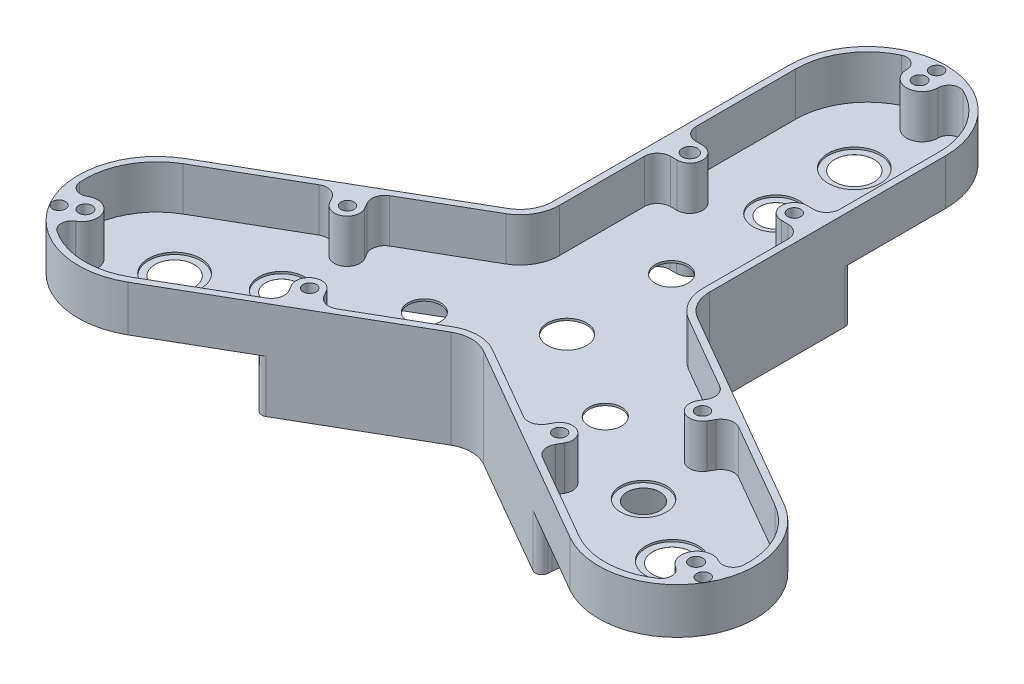
from build123d import *

# Parameters (mm, degrees)
BOSS_EXTRUDE3_DEPTH = 22.225
CUT_EXTRUDE3_DEPTH  = 21.209
SKETCH22_R          = 9.525
CUT_EXTRUDE4_DEPTH  = 22.224746
SKETCH23_R          = 7.9375
CUT_EXTRUDE5_DEPTH  = 22.224746
SKETCH26_R          = 3.673556043
CUT_EXTRUDE8_DEPTH  = 25.4
SKETCH27_R          = 3.175
CUT_EXTRUDE9_DEPTH  = 25.4
SKETCH28_R          = 3.175
CUT_EXTRUDE24_DEPTH = 25.4
SKETCH35_R          = 3.175
SKETCH35_R_2        = 3.2639
CUT_EXTRUDE25_DEPTH = 9.525
SKETCH36_R          = 3.2639
SKETCH36_R_2        = 7.9375
SKETCH36_R_3        = 9.525
CUT_EXTRUDE30_DEPTH = 25.4
SKETCH48_R          = 3.673556043
SKETCH48_R_2        = 7.9375
SKETCH48_R_3        = 3.175
SKETCH48_R_4        = 9.525
BOSS_EXTRUDE4_DEPTH = 25.4
CUT_EXTRUDE31_DEPTH = 25.4
SKETCH50_R          = 3.175
CUT_EXTRUDE32_DEPTH = 9.525
SKETCH55_R          = 11.1125
SKETCH55_R_2        = 12.7
CUT_EXTRUDE36_DEPTH = 0.9906


with BuildPart() as part:
    # Sketch1 → Boss-Extrude3 (new body)
    with BuildSketch(Plane(origin=(0, 0, 0), x_dir=(1, 0, 0), z_dir=(0, 1, 0))):
        with BuildLine():
            Line((-38.1, 31.16248078), (-38.1, 146.05))
            ThreePointArc((-38.1, 146.05), (0, 184.15), (38.1, 146.05))
            Line((38.1, 146.05), (38.1, 31.16248078))
            ThreePointArc((38.1, 31.16248078), (40.226846715, 23.22498078), (46.0375, 17.414327494))
            Line((46.0375, 17.414327494), (145.533010223, -40.029432116))
            ThreePointArc((145.533010223, -40.029432116), (159.478578107, -92.075), (107.433010223, -106.020567884))
            Line((107.433010223, -106.020567884), (7.9375, -48.576808274))
            ThreePointArc((7.9375, -48.576808274), (0, -46.449961559), (-7.9375, -48.576808274))
            Line((-7.9375, -48.576808274), (-107.433010223, -106.020567884))
            ThreePointArc((-107.433010223, -106.020567884), (-159.478578107, -92.075), (-145.533010223, -40.029432116))
            Line((-145.533010223, -40.029432116), (-46.0375, 17.414327494))
            ThreePointArc((-46.0375, 17.414327494), (-40.226846715, 23.22498078), (-38.1, 31.16248078))
        make_face()
    extrude(amount=BOSS_EXTRUDE3_DEPTH)

    # Sketch17 → Cut-Extrude3 (cut)
    with BuildSketch(Plane(origin=(0, 22.225, 0), x_dir=(1, 0, 0), z_dir=(0, 1, 0))):
        with BuildLine():
            ThreePointArc((25.4, 78.86090476), (19.17090476, 85.09), (25.4, 91.31909524))
            Line((25.4, 91.31909524), (28.575, 91.31909524))
            ThreePointArc((28.575, 91.31909524), (33.065128061, 93.178967179), (34.925, 97.66909524))
            Line((34.925, 97.66909524), (34.925, 146.05))
            ThreePointArc((34.925, 146.05), (29.534644698, 164.690289364), (15.027483173, 177.576661328))
            ThreePointArc((15.027483173, 177.576661328), (10.007581005, 177.205607558), (7.619805836, 172.774396841))
            ThreePointArc((7.619805836, 172.774396841), (0.027198595, 165.100048539), (-7.62, 172.719999998))
            ThreePointArc((-7.62, 172.719999998), (-7.619951459, 172.747198592), (-7.619805836, 172.774396841))
            ThreePointArc((-7.619805836, 172.774396841), (-10.007581005, 177.205607558), (-15.027483173, 177.576661328))
            ThreePointArc((-15.027483173, 177.576661328), (-29.534644698, 164.690289364), (-34.925, 146.05))
            Line((-34.925, 146.05), (-34.925, 97.66909524))
            ThreePointArc((-34.925, 97.66909524), (-33.065128061, 93.178967179), (-28.575, 91.31909524))
            Line((-28.575, 91.31909524), (-25.4, 91.31909524))
            ThreePointArc((-25.4, 91.31909524), (-19.17090476, 85.09), (-25.4, 78.86090476))
            Line((-25.4, 78.86090476), (-28.575, 78.86090476))
            ThreePointArc((-28.575, 78.86090476), (-33.065128061, 77.001032821), (-34.925, 72.51090476))
            Line((-34.925, 72.51090476), (-34.925, 31.16248078))
            ThreePointArc((-34.925, 31.16248078), (-37.477216058, 21.63748078), (-44.45, 14.664696837))
            Line((-44.45, 14.664696837), (-80.258785574, -6.009515153))
            ThreePointArc((-80.258785574, -6.009515153), (-83.217414571, -9.865275531), (-82.583046888, -14.683776467))
            Line((-82.583046888, -14.683776467), (-80.995546888, -17.433407124))
            ThreePointArc((-80.995546888, -17.433407124), (-83.275553988, -25.942509464), (-91.784656328, -23.662502364))
            Line((-91.784656328, -23.662502364), (-93.372156328, -20.912871707))
            ThreePointArc((-93.372156328, -20.912871707), (-97.227916706, -17.95424271), (-102.046417642, -18.588610393))
            Line((-102.046417642, -18.588610393), (-143.945510223, -42.779062773))
            ThreePointArc((-143.945510223, -42.779062773), (-157.393296695, -56.767392082), (-161.299641416, -75.774148481))
            ThreePointArc((-161.299641416, -75.774148481), (-158.459050418, -79.917771869), (-153.43691971, -79.788252996))
            ThreePointArc((-153.43691971, -79.788252996), (-142.994435502, -82.526469598), (-145.769907744, -92.959113578))
            Line((-145.769907744, -92.959113578), (-145.900114004, -93.034288197))
            ThreePointArc((-145.900114004, -93.034288197), (-148.463020777, -97.317547011), (-146.272158243, -101.802512847))
            ThreePointArc((-146.272158243, -101.802512847), (-127.858651998, -107.922897282), (-109.020510223, -103.270937227))
            Line((-109.020510223, -103.270937227), (-67.121417642, -79.080484847))
            ThreePointArc((-67.121417642, -79.080484847), (-64.162788645, -75.224724469), (-64.797156328, -70.406223533))
            Line((-64.797156328, -70.406223533), (-66.384656328, -67.656592876))
            ThreePointArc((-66.384656328, -67.656592876), (-64.104649228, -59.147490536), (-55.595546888, -61.427497636))
            Line((-55.595546888, -61.427497636), (-54.008046888, -64.177128293))
            ThreePointArc((-54.008046888, -64.177128293), (-50.15228651, -67.13575729), (-45.333785574, -66.501389607))
            Line((-45.333785574, -66.501389607), (-9.525, -45.827177617))
            ThreePointArc((-9.525, -45.827177617), (0, -43.274961559), (9.525, -45.827177617))
            Line((9.525, -45.827177617), (45.333785574, -66.501389607))
            ThreePointArc((45.333785574, -66.501389607), (50.15228651, -67.13575729), (54.008046888, -64.177128293))
            Line((54.008046888, -64.177128293), (55.595546888, -61.427497636))
            ThreePointArc((55.595546888, -61.427497636), (64.104649228, -59.147490536), (66.384656328, -67.656592876))
            Line((66.384656328, -67.656592876), (64.797156328, -70.406223533))
            ThreePointArc((64.797156328, -70.406223533), (64.162788645, -75.224724469), (67.121417642, -79.080484847))
            Line((67.121417642, -79.080484847), (109.020510223, -103.270937227))
            ThreePointArc((109.020510223, -103.270937227), (127.858651998, -107.922897282), (146.272158243, -101.802512847))
            ThreePointArc((146.272158243, -101.802512847), (148.462560886, -97.306961314), (145.881859604, -93.023524818))
            Line((145.881859604, -93.023524818), (145.817113869, -92.986143851))
            ThreePointArc((145.817113869, -92.986143851), (142.967236903, -82.573578948), (153.38990774, -79.760886427))
            Line((153.38990774, -79.760886427), (153.5201137, -79.836060873))
            ThreePointArc((153.5201137, -79.836060873), (158.51097818, -79.913974091), (161.299641416, -75.774148481))
            ThreePointArc((161.299641416, -75.774148481), (157.393296695, -56.767392082), (143.945510223, -42.779062773))
            Line((143.945510223, -42.779062773), (102.046417642, -18.588610393))
            ThreePointArc((102.046417642, -18.588610393), (97.227916706, -17.95424271), (93.372156328, -20.912871707))
            Line((93.372156328, -20.912871707), (91.784656328, -23.662502364))
            ThreePointArc((91.784656328, -23.662502364), (83.275553988, -25.942509464), (80.995546888, -17.433407124))
            Line((80.995546888, -17.433407124), (82.583046888, -14.683776467))
            ThreePointArc((82.583046888, -14.683776467), (83.217414571, -9.865275531), (80.258785574, -6.009515153))
            Line((80.258785574, -6.009515153), (44.45, 14.664696837))
            ThreePointArc((44.45, 14.664696837), (37.477216058, 21.63748078), (34.925, 31.16248078))
            Line((34.925, 31.16248078), (34.925, 72.51090476))
            ThreePointArc((34.925, 72.51090476), (33.065128061, 77.001032821), (28.575, 78.86090476))
            Line((28.575, 78.86090476), (25.4, 78.86090476))
        make_face()
    extrude(amount=-CUT_EXTRUDE3_DEPTH, mode=Mode.SUBTRACT)

    # Sketch22 → Cut-Extrude4 (cut)
    with BuildSketch(Plane(origin=(0, 1.016, 0), x_dir=(1, 0, 0), z_dir=(0, 1, 0))):
        Circle(SKETCH22_R)
    extrude(amount=-CUT_EXTRUDE4_DEPTH, mode=Mode.SUBTRACT)

    # Sketch23 → Cut-Extrude5 (cut)
    with BuildSketch(Plane(origin=(0, 1.016, 0), x_dir=(1, 0, 0), z_dir=(0, 1, 0))):
        with Locations((0, 50.8)):
            Circle(SKETCH23_R)
        with Locations((43.994090512, -25.4)):
            Circle(SKETCH23_R)
        with Locations((-43.994090512, -25.4)):
            Circle(SKETCH23_R)
    extrude(amount=-CUT_EXTRUDE5_DEPTH, mode=Mode.SUBTRACT)

    # Sketch26 → Cut-Extrude8 (cut)
    with BuildSketch(Plane(origin=(0, 22.225, 0), x_dir=(1, 0, 0), z_dir=(0, 1, 0))):
        with Locations((-25.4, 85.09)):
            Circle(SKETCH26_R)
    extrude(amount=-CUT_EXTRUDE8_DEPTH, mode=Mode.SUBTRACT)

    # Sketch27 → Cut-Extrude9 (cut)
    with BuildSketch(Plane(origin=(0, 22.225, 0), x_dir=(1, 0, 0), z_dir=(0, 1, 0))):
        with Locations((25.4, 85.09)):
            Circle(SKETCH27_R)
    extrude(amount=-CUT_EXTRUDE9_DEPTH, mode=Mode.SUBTRACT)

    # Sketch28 → Cut-Extrude24 (cut)
    with BuildSketch(Plane(origin=(0, 22.225, 0), x_dir=(1, 0, 0), z_dir=(0, 1, 0))):
        with Locations((-86.285395014, -20.487502364)):
            Circle(SKETCH28_R)
        with Locations((-60.73873104, -64.396916391)):
            Circle(SKETCH28_R)
        with Locations((60.885395014, -64.481592876)):
            Circle(SKETCH28_R)
        with Locations((86.460019457, -20.588321833)):
            Circle(SKETCH28_R)
    extrude(amount=-CUT_EXTRUDE24_DEPTH, mode=Mode.SUBTRACT)

    # Sketch35 → Cut-Extrude25 (cut)
    with BuildSketch(Plane(origin=(0, 22.225, 0), x_dir=(1, 0, 0), z_dir=(0, 1, 0))):
        with Locations((0, 179.705)):
            Circle(SKETCH35_R)
        with Locations((156.618962224, -90.424)):
            Circle(SKETCH35_R)
        with Locations((-156.618962224, -90.424)):
            Circle(SKETCH35_R)
        with Locations((0, 171.45)):
            Circle(SKETCH35_R_2)
    extrude(amount=-CUT_EXTRUDE25_DEPTH, mode=Mode.SUBTRACT)

    # Sketch36 → Cut-Extrude30 (cut)
    with BuildSketch(Plane(origin=(0, 22.225, 0), x_dir=(1, 0, 0), z_dir=(0, 1, 0))):
        with Locations((0, 171.45)):
            Circle(SKETCH36_R)
        with Locations((148.480055479, -85.725)):
            Circle(SKETCH36_R)
        with Locations((-148.480055479, -85.725)):
            Circle(SKETCH36_R)
        with Locations((0, 50.8)):
            Circle(SKETCH36_R_2)
        with Locations((0, 101.6)):
            Circle(SKETCH36_R_2)
        with Locations((0, 139.7)):
            Circle(SKETCH36_R_3)
        with Locations((120.983748909, -69.85)):
            Circle(SKETCH36_R_3)
        with Locations((87.988181025, -50.8)):
            Circle(SKETCH36_R_2)
        with Locations((-120.983748909, -69.85)):
            Circle(SKETCH36_R_3)
        with Locations((-87.988181024, -50.8)):
            Circle(SKETCH36_R_2)
    extrude(amount=-CUT_EXTRUDE30_DEPTH, mode=Mode.SUBTRACT)

    # Sketch48 → Boss-Extrude4 (add)
    with BuildSketch(Plane.XZ):
        with BuildLine():
            Line((64.934223532, 81.483881948), (7.9375, 48.576808274))
            ThreePointArc((7.9375, 48.576808274), (0, 46.449961559), (-7.9375, 48.576808274))
            Line((-7.9375, 48.576808274), (-64.934223532, 81.483881948))
            ThreePointArc((-64.934223532, 81.483881948), (-68.045575265, 81.51965986), (-69.693365764, 78.880232623))
            Line((-69.693365764, 78.880232623), (-69.775610399, 77.093356509))
            ThreePointArc((-69.775610399, 77.093356509), (-79.662299395, 45.99305), (-101.652610399, 21.880772916))
            Line((-101.652610399, 21.880772916), (-103.15896819, 20.916108915))
            ThreePointArc((-103.15896819, 20.916108915), (-104.620883979, 18.169366865), (-103.034223532, 15.49274618))
            Line((-103.034223532, 15.49274618), (-46.0375, -17.414327494))
            ThreePointArc((-46.0375, -17.414327494), (-40.226846715, -23.224980779), (-38.1, -31.162480779))
            Line((-38.1, -31.162480779), (-38.1, -96.976628128))
            ThreePointArc((-38.1, -96.976628128), (-36.575308714, -99.689026724), (-33.465602426, -99.796341539))
            Line((-33.465602426, -99.796341539), (-31.877, -98.974129424))
            ThreePointArc((-31.877, -98.974129424), (0, -91.9861), (31.877, -98.974129424))
            Line((31.877, -98.974129424), (33.465602426, -99.796341539))
            ThreePointArc((33.465602426, -99.796341539), (36.575308714, -99.689026724), (38.1, -96.976628128))
            Line((38.1, -96.976628128), (38.1, -31.16248078))
            ThreePointArc((38.1, -31.16248078), (40.226846715, -23.22498078), (46.0375, -17.414327494))
            Line((46.0375, -17.414327494), (103.034223532, 15.49274618))
            ThreePointArc((103.034223532, 15.49274618), (104.620883979, 18.169366865), (103.15896819, 20.916108915))
            Line((103.15896819, 20.916108915), (101.652610399, 21.880772916))
            ThreePointArc((101.652610399, 21.880772916), (79.662299395, 45.99305), (69.775610399, 77.093356508))
            Line((69.775610399, 77.093356508), (69.693365764, 78.880232623))
            ThreePointArc((69.693365764, 78.880232623), (68.045575265, 81.51965986), (64.934223532, 81.483881948))
        make_face()
        with Locations((-25.4, -85.09)):
            Circle(SKETCH48_R, mode=Mode.SUBTRACT)
        with Locations((0, -50.8)):
            Circle(SKETCH48_R_2, mode=Mode.SUBTRACT)
        with Locations((25.4, -85.09)):
            Circle(SKETCH48_R_3, mode=Mode.SUBTRACT)
        with Locations((-86.285395014, 20.487502364)):
            Circle(SKETCH48_R_3, mode=Mode.SUBTRACT)
        Circle(SKETCH48_R_4, mode=Mode.SUBTRACT)
        with Locations((-43.994090512, 25.4)):
            Circle(SKETCH48_R_2, mode=Mode.SUBTRACT)
        with Locations((-60.73873104, 64.396916391)):
            Circle(SKETCH48_R_3, mode=Mode.SUBTRACT)
        with Locations((43.994090512, 25.4)):
            Circle(SKETCH48_R_2, mode=Mode.SUBTRACT)
        with Locations((86.460019457, 20.588321833)):
            Circle(SKETCH48_R_3, mode=Mode.SUBTRACT)
        with Locations((60.885395014, 64.481592876)):
            Circle(SKETCH48_R_3, mode=Mode.SUBTRACT)
    extrude(amount=BOSS_EXTRUDE4_DEPTH)

    # Sketch49 → Cut-Extrude31 (cut)
    with BuildSketch(Plane.XZ.offset(25.4)):
        with BuildLine():
            Line((55.3861337, 61.306592876), (53.7986337, 64.056223533))
            ThreePointArc((53.7986337, 64.056223533), (49.942873323, 67.01485253), (45.124372386, 66.380484847))
            Line((45.124372386, 66.380484847), (9.525, 45.827177617))
            Line((9.525, 45.827177617), (8.122207895, 45.017275217))
            ThreePointArc((8.122207895, 45.017275217), (0.765194607, 42.901045118), (-6.726805893, 44.47394145))
            Line((-6.726805893, 44.47394145), (-9.525, 45.827177617))
            Line((-9.525, 45.827177617), (-45.124372386, 66.380484847))
            ThreePointArc((-45.124372386, 66.380484847), (-49.942873323, 67.01485253), (-53.7986337, 64.056223533))
            Line((-53.7986337, 64.056223533), (-55.3861337, 61.306592876))
            ThreePointArc((-55.3861337, 61.306592876), (-57.710395014, 58.982331562), (-60.885395014, 58.131592876))
            Line((-60.885395014, 58.131592876), (-66.336321036, 58.131592876))
            ThreePointArc((-66.336321036, 58.131592876), (-69.469372125, 57.30486101), (-71.78661434, 55.039936459))
            ThreePointArc((-71.78661434, 55.039936459), (-76.912668738, 44.40555), (-83.559290366, 34.649063441))
            ThreePointArc((-83.559290366, 34.649063441), (-84.362151457, 31.50981054), (-83.511596711, 28.383142773))
            Line((-83.511596711, 28.383142773), (-80.7861337, 23.662502364))
            ThreePointArc((-80.7861337, 23.662502364), (-79.935395014, 20.487502364), (-80.7861337, 17.312502364))
            Line((-80.7861337, 17.312502364), (-82.3736337, 14.562871707))
            ThreePointArc((-82.3736337, 14.562871707), (-83.008001383, 9.74437077), (-80.049372386, 5.888610393))
            Line((-80.049372386, 5.888610393), (-44.45, -14.664696837))
            Line((-44.45, -14.664696837), (-43.047207895, -15.474599237))
            ThreePointArc((-43.047207895, -15.474599237), (-37.535992224, -20.787844591), (-35.152160156, -28.062555515))
            Line((-35.152160156, -28.062555515), (-34.925, -31.16248078))
            Line((-34.925, -31.16248078), (-34.925, -72.26909524))
            ThreePointArc((-34.925, -72.26909524), (-33.065128061, -76.7592233), (-28.575, -78.61909524))
            Line((-28.575, -78.61909524), (-25.4, -78.61909524))
            ThreePointArc((-25.4, -78.61909524), (-22.225, -79.469833926), (-19.900738686, -81.79409524))
            Line((-19.900738686, -81.79409524), (-17.175275675, -86.514735649))
            ThreePointArc((-17.175275675, -86.514735649), (-14.892779332, -88.81467155), (-11.772676026, -89.688999899))
            ThreePointArc((-11.772676026, -89.688999899), (0, -88.8111), (11.772676026, -89.688999899))
            ThreePointArc((11.772676026, -89.688999899), (14.892779332, -88.81467155), (17.175275675, -86.514735649))
            Line((17.175275675, -86.514735649), (19.900738686, -81.79409524))
            ThreePointArc((19.900738686, -81.79409524), (22.225, -79.469833926), (25.4, -78.61909524))
            Line((25.4, -78.61909524), (28.575, -78.61909524))
            ThreePointArc((28.575, -78.61909524), (33.065128061, -76.7592233), (34.925, -72.26909524))
            Line((34.925, -72.26909524), (34.925, -31.16248078))
            Line((34.925, -31.16248078), (35.152160156, -28.062555515))
            ThreePointArc((35.152160156, -28.062555515), (37.535992224, -20.787844591), (43.047207895, -15.474599237))
            Line((43.047207895, -15.474599237), (44.45, -14.664696837))
            Line((44.45, -14.664696837), (80.049372386, 5.888610393))
            ThreePointArc((80.049372386, 5.888610393), (83.008001383, 9.74437077), (82.3736337, 14.562871707))
            Line((82.3736337, 14.562871707), (80.7861337, 17.312502364))
            ThreePointArc((80.7861337, 17.312502364), (79.935395014, 20.487502364), (80.7861337, 23.662502364))
            Line((80.7861337, 23.662502364), (83.511596711, 28.383142773))
            ThreePointArc((83.511596711, 28.383142773), (84.362151457, 31.50981054), (83.559290366, 34.649063441))
            ThreePointArc((83.559290366, 34.649063441), (76.912668738, 44.40555), (71.78661434, 55.039936459))
            ThreePointArc((71.78661434, 55.039936459), (69.469372125, 57.30486101), (66.336321036, 58.131592876))
            Line((66.336321036, 58.131592876), (60.885395014, 58.131592876))
            ThreePointArc((60.885395014, 58.131592876), (57.710395014, 58.982331562), (55.3861337, 61.306592876))
        make_face()
    extrude(amount=-CUT_EXTRUDE31_DEPTH, mode=Mode.SUBTRACT)

    # Sketch50 → Cut-Extrude32 (cut)
    with BuildSketch(Plane(origin=(0, -25.4, 0), x_dir=(-1, 0, 0), z_dir=(0, -1, 0))):
        with Locations((-65.035301623, -74.356537961)):
            Circle(SKETCH50_R)
        with Locations((-96.912301623, -19.143954368)):
            Circle(SKETCH50_R)
        with Locations((-31.877, 93.500492328)):
            Circle(SKETCH50_R)
        with Locations((31.877, 93.500492328)):
            Circle(SKETCH50_R)
        with Locations((65.035301623, -74.356537961)):
            Circle(SKETCH50_R)
        with Locations((96.912301623, -19.143954368)):
            Circle(SKETCH50_R)
    extrude(amount=-CUT_EXTRUDE32_DEPTH, mode=Mode.SUBTRACT)

    # Sketch55 → Cut-Extrude36 (cut)
    with BuildSketch(Plane(origin=(0, 1.016, 0), x_dir=(1, 0, 0), z_dir=(0, 1, 0))):
        with Locations((0, 101.6)):
            Circle(SKETCH55_R)
        with Locations((0, 139.7)):
            Circle(SKETCH55_R_2)
        with Locations((87.988181025, -50.8)):
            Circle(SKETCH55_R)
        with Locations((120.983748909, -69.85)):
            Circle(SKETCH55_R_2)
        with Locations((-87.988181024, -50.8)):
            Circle(SKETCH55_R)
        with Locations((-120.983748909, -69.85)):
            Circle(SKETCH55_R_2)
    extrude(amount=-CUT_EXTRUDE36_DEPTH, mode=Mode.SUBTRACT)


solid = part.part
